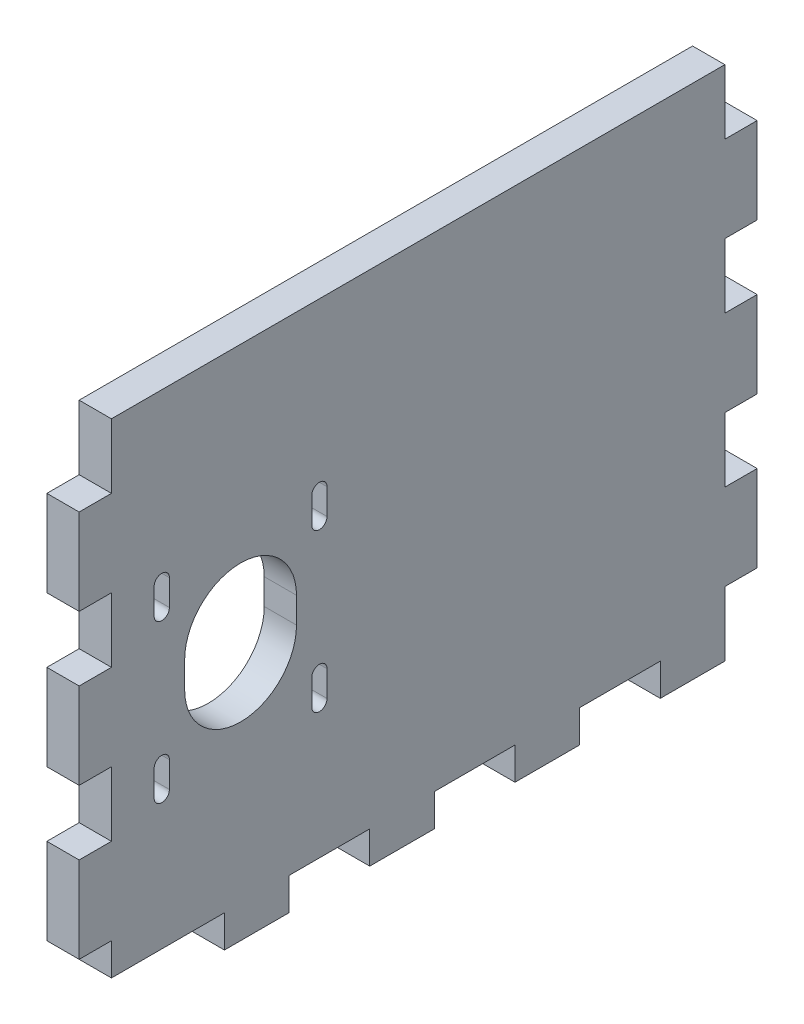
from build123d import *

# Parameters (mm, degrees)
SKETCH1_W               = 44.958
SKETCH1_H               = 304.8
BOSS_EXTRUDE1_DEPTH     = 6.35
SKETCH2_W               = 6.35
SKETCH2_H               = 101.6
BOSS_EXTRUDE2_DEPTH     = 6.35
SKETCH3_W               = 120.65
SKETCH3_H               = 6.35
BOSS_EXTRUDE3_DEPTH     = 38.608
SKETCH8_W               = 6.35
SKETCH8_H               = 213.451350416
CUT_EXTRUDE4_DEPTH      = 1
CUT_EXTRUDE4_DEPTH_BACK = 134.35
SKETCH6_W               = 6.35
SKETCH6_H               = 12.7
CUT_EXTRUDE5_DEPTH      = 6.35
SKETCH4_3_W             = 6.35
SKETCH4_3_H             = 15.875
SKETCH4_3_H_2           = 6.35
CUT_EXTRUDE6_DEPTH      = 6.35


with BuildPart() as part:
    # Sketch1 → Boss-Extrude1 (new body)
    with BuildSketch(Plane.XY):
        with Locations((-6.477, 3.048)):
            Rectangle(SKETCH1_W, SKETCH1_H)
        with BuildLine():
            Line((-3.302, 133.858), (-3.302, -143.002))
            Line((-3.302, -143.002), (3.302, -143.002))
            Line((3.302, -143.002), (3.302, 143.002))
            Line((3.302, 143.002), (-16.256, 143.002))
            Line((-16.256, 143.002), (-16.256, 136.398))
            Line((-16.256, 136.398), (-5.842, 136.398))
            ThreePointArc((-5.842, 136.398), (-4.045948776, 135.654051224), (-3.302, 133.858))
        make_face(mode=Mode.SUBTRACT)
    extrude(amount=BOSS_EXTRUDE1_DEPTH)

    # Sketch2 → Boss-Extrude2 (add)
    with BuildSketch(Plane(origin=(16.002, 0, 0), x_dir=(0, 0, -1), z_dir=(1, 0, 0))):
        Polygon((120.65, -60.452), (120.65, -47.752), (0, -47.752), (0, -149.352), (120.65, -149.352), (120.65, -136.652), (127, -136.652), (127, -119.718666667), (120.65, -119.718666667), (120.65, -107.018666667), (127, -107.018666667), (127, -90.085333333), (120.65, -90.085333333), (120.65, -77.385333333), (127, -77.385333333), (127, -60.452), align=None)
        with BuildLine():
            ThreePointArc((11.4, -116.592), (9.9, -118.092), (8.4, -116.592))
            Line((8.4, -116.592), (8.4, -111.512))
            ThreePointArc((8.4, -111.512), (9.9, -110.012), (11.4, -111.512))
            Line((11.4, -111.512), (11.4, -116.592))
        make_face(mode=Mode.SUBTRACT)
        with BuildLine():
            Line((42.4, -111.512), (42.4, -116.592))
            ThreePointArc((42.4, -116.592), (40.9, -118.092), (39.4, -116.592))
            Line((39.4, -116.592), (39.4, -111.512))
            ThreePointArc((39.4, -111.512), (40.9, -110.012), (42.4, -111.512))
        make_face(mode=Mode.SUBTRACT)
        with BuildLine():
            ThreePointArc((36.4, -101.092), (25.4, -112.092), (14.4, -101.092))
            Line((14.4, -101.092), (14.4, -96.012))
            ThreePointArc((14.4, -96.012), (25.4, -85.012), (36.4, -96.012))
            Line((36.4, -96.012), (36.4, -101.092))
        make_face(mode=Mode.SUBTRACT)
        with BuildLine():
            ThreePointArc((11.4, -85.592), (9.9, -87.092), (8.4, -85.592))
            Line((8.4, -85.592), (8.4, -80.512))
            ThreePointArc((8.4, -80.512), (9.9, -79.012), (11.4, -80.512))
            Line((11.4, -80.512), (11.4, -85.592))
        make_face(mode=Mode.SUBTRACT)
        with BuildLine():
            ThreePointArc((42.4, -85.592), (40.9, -87.092), (39.4, -85.592))
            Line((39.4, -85.592), (39.4, -80.512))
            ThreePointArc((39.4, -80.512), (40.9, -79.012), (42.4, -80.512))
            Line((42.4, -80.512), (42.4, -85.592))
        make_face(mode=Mode.SUBTRACT)
        with Locations((-3.175, -98.552)):
            Rectangle(SKETCH2_W, SKETCH2_H)
    extrude(amount=-BOSS_EXTRUDE2_DEPTH)

    # Sketch3 → Boss-Extrude3 (add)
    with BuildSketch(Plane.ZY.offset(-9.652)):
        with Locations((-60.325, -146.177)):
            Rectangle(SKETCH3_W, SKETCH3_H)
    extrude(amount=BOSS_EXTRUDE3_DEPTH)

    # Sketch8 → Cut-Extrude4 (cut, two sides)
    with BuildSketch(Plane.XY.offset(6.35)) as cut_extrude4_sk:
        Polygon((-28.956, -149.352), (9.652, -149.352), (9.652, -47.752), (9.652, 155.448), (-28.956, 155.448), align=None)
        with BuildLine():
            Line((-16.256, 136.398), (-16.256, 143.002))
            Line((-16.256, 143.002), (3.302, 143.002))
            Line((3.302, 143.002), (3.302, -143.002))
            Line((3.302, -143.002), (-3.302, -143.002))
            Line((-3.302, -143.002), (-3.302, 133.858))
            ThreePointArc((-3.302, 133.858), (-4.045948776, 135.654051224), (-5.842, 136.398))
            Line((-5.842, 136.398), (-16.256, 136.398))
        make_face(mode=Mode.SUBTRACT)
        Polygon((-54.223542679, -149.352), (-28.956, -149.352), (-28.956, 155.448), (9.652, 155.448), (9.652, 165.699350416), (-54.223542679, 165.699350416), align=None)
        with Locations((12.827, 58.973675208)):
            Rectangle(SKETCH8_W, SKETCH8_H)
    extrude(amount=CUT_EXTRUDE4_DEPTH, mode=Mode.SUBTRACT)
    extrude(cut_extrude4_sk.sketch, amount=-CUT_EXTRUDE4_DEPTH_BACK, mode=Mode.SUBTRACT)

    # Sketch6 → Cut-Extrude5 (cut)
    with BuildSketch(Plane.XY.offset(6.35)):
        with Locations((12.827, -54.102)):
            Rectangle(SKETCH6_W, SKETCH6_H)
        with Locations((12.827, -83.735333333)):
            Rectangle(SKETCH6_W, SKETCH6_H)
        with Locations((12.827, -113.368666667)):
            Rectangle(SKETCH6_W, SKETCH6_H)
        with Locations((12.827, -143.002)):
            Rectangle(SKETCH6_W, SKETCH6_H)
    extrude(amount=-CUT_EXTRUDE5_DEPTH, mode=Mode.SUBTRACT)

    # Sketch4_3 → Cut-Extrude6 (cut)
    with BuildSketch(Plane.XZ.offset(149.352)):
        with Locations((12.827, -100.0125)):
            Rectangle(SKETCH4_3_W, SKETCH4_3_H)
        with Locations((12.827, -71.4375)):
            Rectangle(SKETCH4_3_W, SKETCH4_3_H)
        with Locations((12.827, -42.8625)):
            Rectangle(SKETCH4_3_W, SKETCH4_3_H)
        with Locations((12.827, -14.2875)):
            Rectangle(SKETCH4_3_W, SKETCH4_3_H)
        with Locations((12.827, 3.175)):
            Rectangle(SKETCH4_3_W, SKETCH4_3_H_2)
        with Locations((12.827, -3.175)):
            Rectangle(SKETCH4_3_W, SKETCH4_3_H_2)
    extrude(amount=-CUT_EXTRUDE6_DEPTH, mode=Mode.SUBTRACT)


solid = part.part
